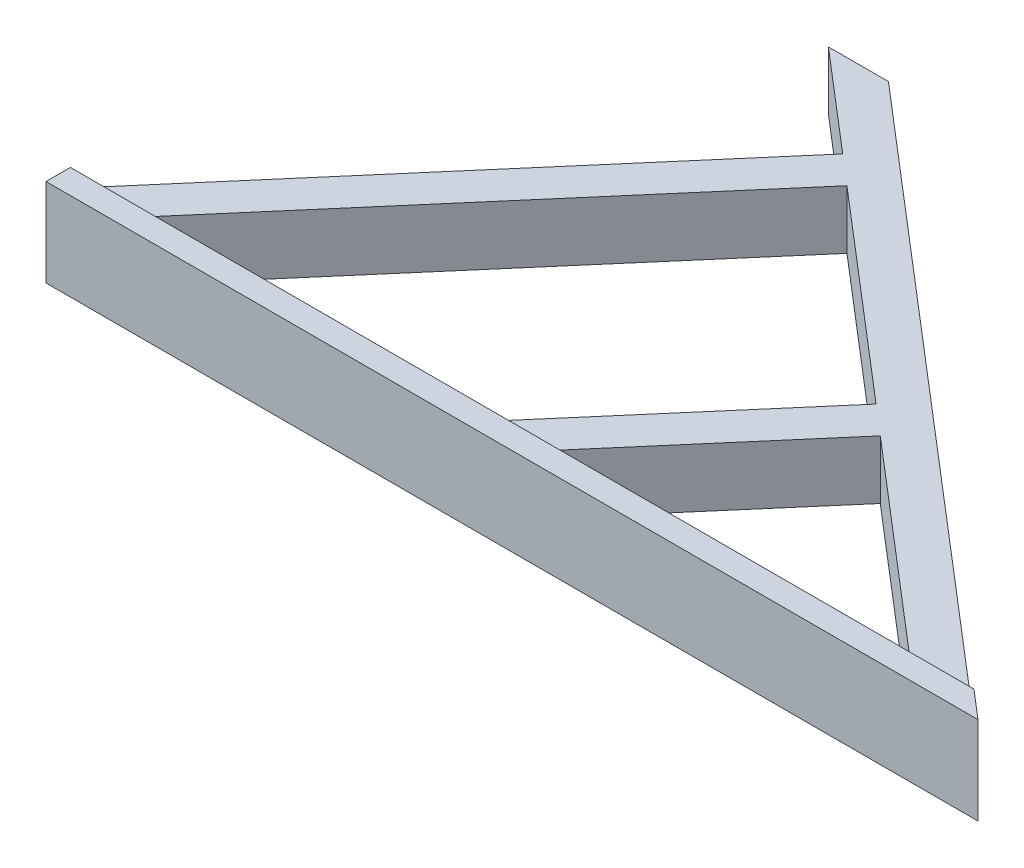
from build123d import *

# Parameters (mm, degrees)
SALIENTE_EXTRUIR1_DEPTH = 6
SALIENTE_EXTRUIR2_DEPTH = 3


with BuildPart() as part:
    # Croquis1 → Saliente-Extruir1 (new body)
    with BuildSketch(Plane(origin=(0, 0, 0), x_dir=(1, 0, 0), z_dir=(0, 1, 0))):
        Polygon((-3.602218893, 50), (2.544306114, 50), (66.713907176, -5), (-28.729177989, -5), (-28.729177989, 0), (6.61797667, 41.240232966), align=None)
        Polygon((-23.460968903, 0), (12.711587976, 0), (30.508284771, 20.763762429), (9.655061899, 38.637136097), align=None, mode=Mode.SUBTRACT)
        Polygon((54.733782073, 0), (33.54537, 18.160665559), (17.979797062, 0), align=None, mode=Mode.SUBTRACT)
    extrude(amount=SALIENTE_EXTRUIR1_DEPTH)

    # Croquis2 → Saliente-Extruir2 (add)
    with BuildSketch(Plane(origin=(0, 6, 0), x_dir=(1, 0, 0), z_dir=(0, 1, 0))):
        Polygon((-28.729177989, -5), (66.713907176, -5), (63.797107127, -2.5), (-28.729177989, -2.5), align=None)
    extrude(amount=SALIENTE_EXTRUIR2_DEPTH)


solid = part.part
